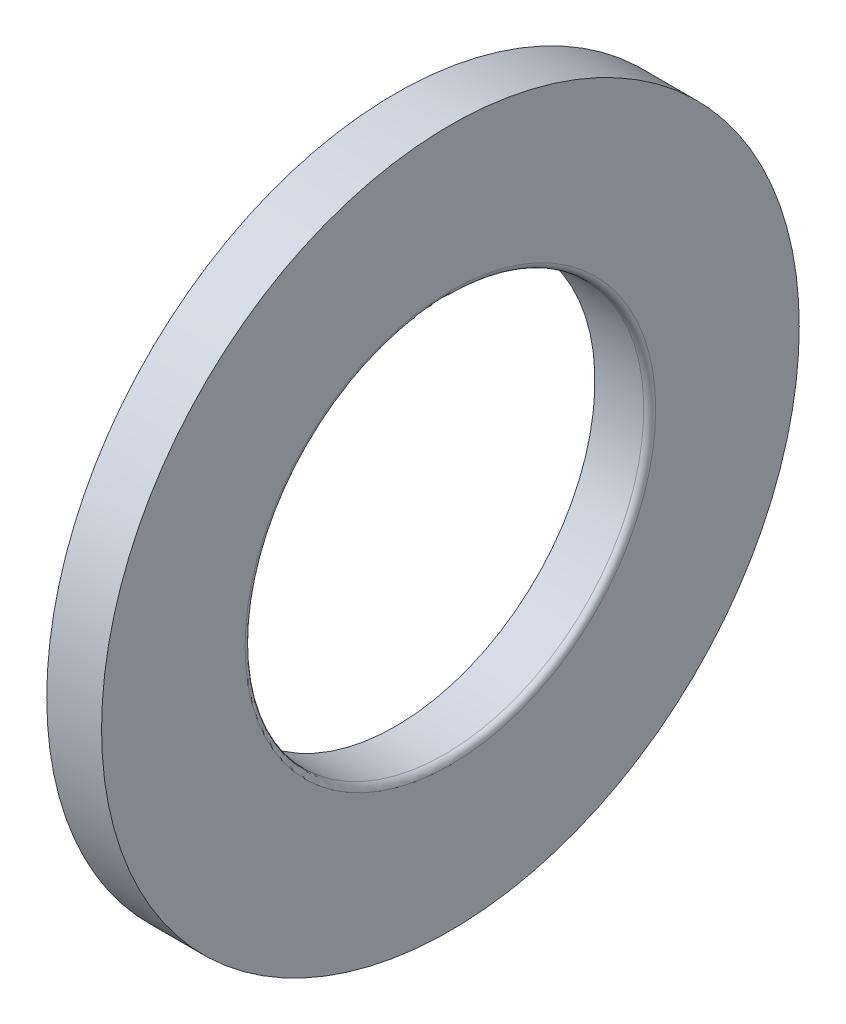
from build123d import *


with BuildPart() as part:
    # Sketch1 → Revolve1 (revolve)
    with BuildSketch(Plane.XY):
        with BuildLine():
            Line((1, 10), (3.45, 10))
            ThreePointArc((3.45, 10), (3.662132034, 10.087867966), (3.75, 10.3))
            Line((3.75, 10.3), (3.75, 17.5))
            Line((3.75, 17.5), (1, 17.5))
            Line((1, 17.5), (1, 10))
        make_face()
    revolve(axis=Axis((50, 0, 0), (-1, 0, 0)))


solid = part.part
